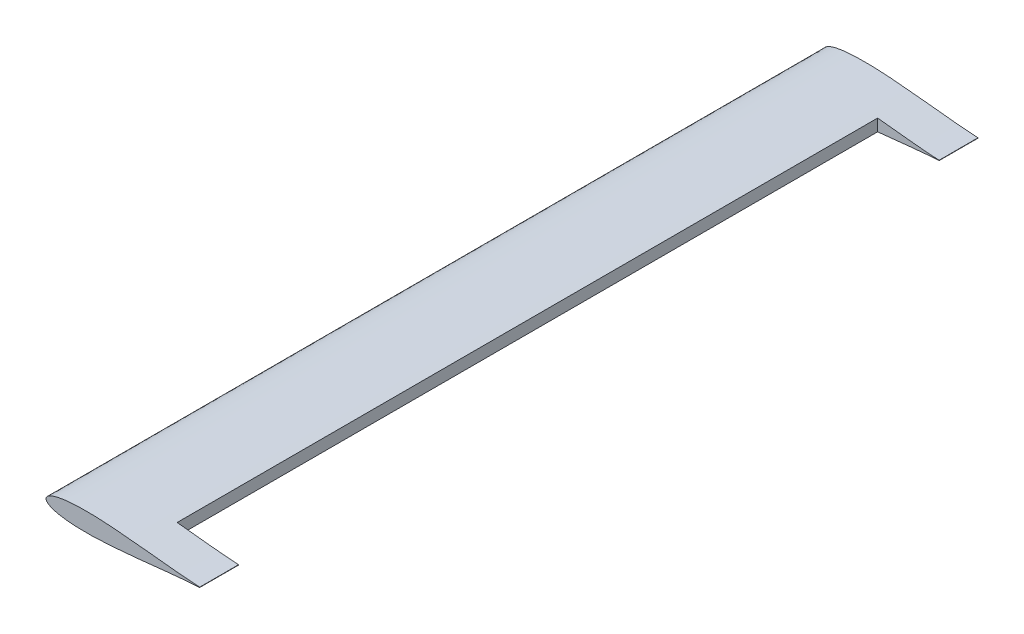
from build123d import *

# Parameters (mm, degrees)
BOSS_EXTRUDE4_DEPTH     = 609.6
SKETCH4_W               = 99.336527046
SKETCH4_H               = 548.64
CUT_EXTRUDE1_DEPTH      = 8.343140111
CUT_EXTRUDE1_DEPTH_BACK = 8.343140106


with BuildPart() as part:
    # Sketch2 → Boss-Extrude4 (new body)
    with BuildSketch(Plane.XY):
        with BuildLine():
            Line((120.380960043, 0.131910968), (120.380960043, -0.13191095))
            add(Edge.make_bspline(
                [(120.380960043, 0.131910968), (119.946341591, 0.152711182), (118.879825678, 0.207805593), (117.085778754, 0.313677955), (114.917831353, 0.458373703), (112.492651454, 0.638201877), (109.822798753, 0.85371931), (106.921074515, 1.105960198), (103.801681225, 1.393960866), (100.47971538, 1.715903258), (96.971509885, 2.06983989), (93.294019085, 2.451783389), (89.46526698, 2.85749965), (85.503826568, 3.28175384), (81.429064058, 3.718670433), (77.260785731, 4.161966443), (73.019254019, 4.604126338), (68.725181462, 5.03833015), (64.399395462, 5.456362411), (60.063068942, 5.851187181), (55.737197625, 6.214504538), (51.442917043, 6.539202929), (47.201068222, 6.818142459), (43.032378562, 7.044765483), (38.957075624, 7.213123875), (34.99505353, 7.318061293), (31.165536986, 7.354994119), (27.487176119, 7.320854727), (23.977851472, 7.213318692), (20.654583842, 7.030920877), (17.533565736, 6.773866125), (14.629816575, 6.443235187), (11.957394826, 6.041513529), (9.529072463, 5.571825351), (7.356345225, 5.038900712), (5.449154243, 4.448412935), (3.815756487, 3.806735364), (2.462434378, 3.120688392), (1.392845645, 2.396403236), (0.609563184, 1.636816588), (0.117367124, 0.838378891), (-0.055284763, 3e-09), (0.117367124, -0.838378885), (0.609563184, -1.636816583), (1.392845646, -2.396403226), (2.462434375, -3.120688405), (3.815756504, -3.806735267), (5.449154164, -4.44841335), (7.35634558, -5.03889881), (9.529110457, -5.571843411), (11.957441548, -6.041483938), (14.629855539, -6.443250824), (17.533566272, -6.773862839), (20.654583684, -7.030921839), (23.977851518, -7.213318406), (27.487176105, -7.320854803), (31.165536989, -7.354994091), (34.995053529, -7.318061295), (38.957075624, -7.213123869), (43.032378562, -7.044765479), (47.201068221, -6.818142456), (51.442917042, -6.539202923), (55.737197626, -6.214504544), (60.063068938, -5.851187144), (64.399395475, -5.456362534), (68.725181412, -5.038329681), (73.019254201, -4.604128053), (77.260826096, -4.161955886), (81.429107504, -3.718688804), (85.503866958, -3.281743582), (89.46526714, -2.857501142), (93.294019045, -2.45178302), (96.971509892, -2.069839946), (100.479715387, -1.715903365), (103.80168119, -1.393960421), (106.921074635, -1.105961717), (109.82283955, -0.853710658), (112.492693973, -0.638215275), (114.917872344, -0.458367158), (117.085778817, -0.313678794), (118.879825669, -0.207805471), (119.946341589, -0.152711137), (120.380960043, -0.13191095)],
                knots=[0.016066336, 0.016066336, 0.016066336, 0.016066336, 0.021198496, 0.028708349, 0.037278223, 0.046867658, 0.057430489, 0.068916541, 0.081270768, 0.094432341, 0.108338211, 0.122918813, 0.138103257, 0.15381535, 0.169977616, 0.186508903, 0.203327313, 0.220348626, 0.237487597, 0.254659894, 0.271779428, 0.288762762, 0.305526624, 0.321990034, 0.338073446, 0.353702279, 0.368802604, 0.383306141, 0.397148829, 0.410269485, 0.422614248, 0.43413286, 0.444782857, 0.454526749, 0.463337037, 0.471194285, 0.478091852, 0.484041802, 0.489081613, 0.493295092, 0.496841712, 0.500000002, 0.503158291, 0.506704912, 0.510918391, 0.515958202, 0.521908151, 0.528805719, 0.536662967, 0.545473255, 0.555217627, 0.56586714, 0.577385752, 0.589730516, 0.602851171, 0.61669386, 0.631197396, 0.646297721, 0.661926555, 0.678009966, 0.694473376, 0.711237238, 0.728220572, 0.745340106, 0.762512403, 0.779651374, 0.796672688, 0.813491097, 0.830022871, 0.84618465, 0.861896743, 0.877081188, 0.891661789, 0.90556766, 0.918729232, 0.93108346, 0.942569511, 0.953132831, 0.962721777, 0.971291651, 0.978801504, 0.983933664, 0.983933664, 0.983933664, 0.983933664], degree=3))
        make_face()
    extrude(amount=BOSS_EXTRUDE4_DEPTH)

    # Sketch4 → Cut-Extrude1 (cut, two sides)
    with BuildSketch(Plane(origin=(0, 0, 0), x_dir=(1, 0, 0), z_dir=(0, 1, 0))) as cut_extrude1_sk:
        with Locations((121.900983566, -304.8)):
            Rectangle(SKETCH4_W, SKETCH4_H)
    extrude(amount=CUT_EXTRUDE1_DEPTH, mode=Mode.SUBTRACT)
    extrude(cut_extrude1_sk.sketch, amount=-CUT_EXTRUDE1_DEPTH_BACK, mode=Mode.SUBTRACT)


solid = part.part
